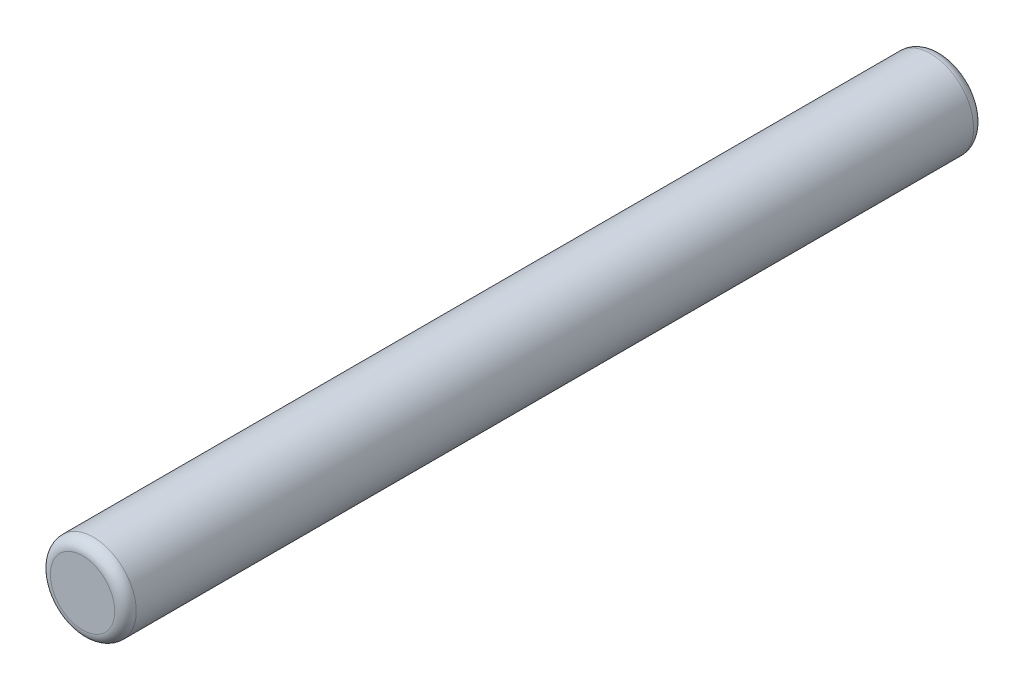
from build123d import *

# Parameters (mm, degrees)
SKETCH_1_R      = 2
EXTRUDE_1_DEPTH = 40
FILLET_1_R      = 0.5


with BuildPart() as part:
    # 草图1 → 凸台-拉伸1 (new body)
    with BuildSketch(Plane.XY):
        Circle(SKETCH_1_R)
    extrude(amount=EXTRUDE_1_DEPTH)

    # 圆角1
    fillet_1_edges = [part.edges().sort_by_distance(p)[0] for p in [
        (-2, 0, 0),
        (-2, 0, 40),
    ]]
    fillet(fillet_1_edges, radius=FILLET_1_R)


solid = part.part
